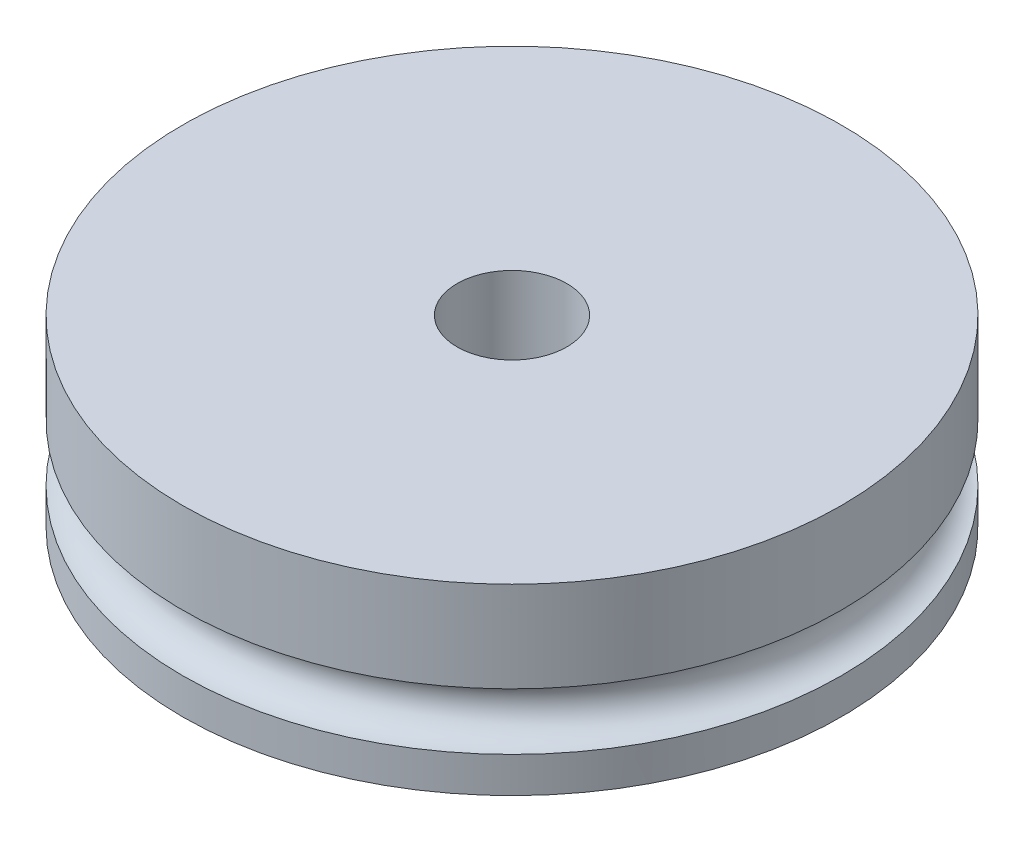
from build123d import *

# Parameters (mm, degrees)
SKETCH1_R           = 18
BOSS_EXTRUDE1_DEPTH = 10
SKETCH2_R           = 1.55
SKETCH4_R           = 3
CUT_EXTRUDE1_DEPTH  = 8


with BuildPart() as part:
    # Sketch1 → Boss-Extrude1 (new body)
    with BuildSketch(Plane(origin=(0, 0, 0), x_dir=(1, 0, 0), z_dir=(0, 1, 0))):
        Circle(SKETCH1_R)
    extrude(amount=BOSS_EXTRUDE1_DEPTH)

    # Sketch2 → Cut-Revolve1 (revolve, cut)
    with BuildSketch(Plane.XY):
        with Locations((18, 3.5)):
            Circle(SKETCH2_R)
    revolve(axis=Axis((0, 0, 0), (0, 1, 0)), mode=Mode.SUBTRACT)

    # Sketch4 → Cut-Extrude1 (cut)
    with BuildSketch(Plane(origin=(0, 10, 0), x_dir=(1, 0, 0), z_dir=(0, 1, 0))):
        Circle(SKETCH4_R)
    extrude(amount=-CUT_EXTRUDE1_DEPTH, mode=Mode.SUBTRACT)


solid = part.part
